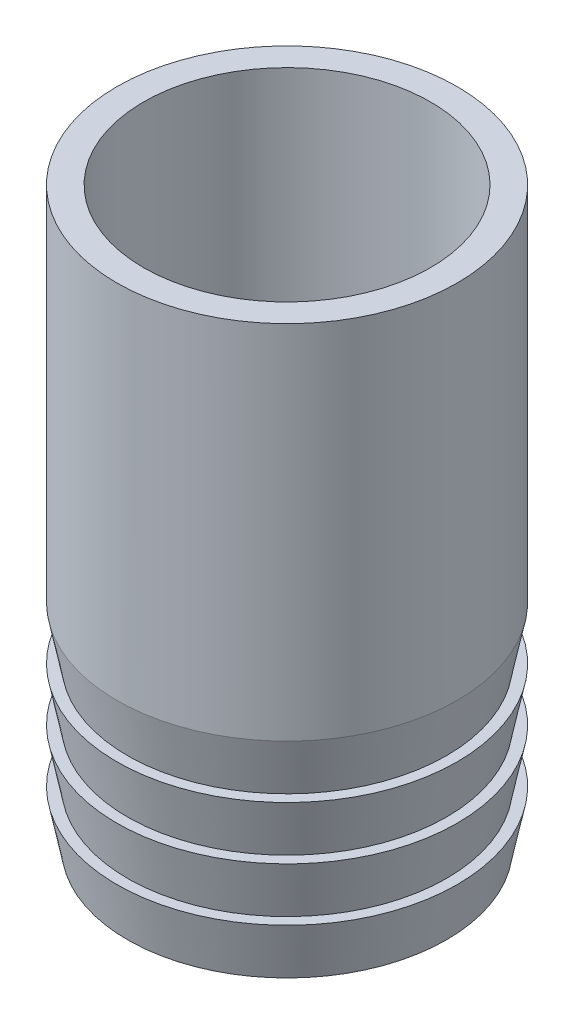
from build123d import *

# Parameters (mm, degrees)
SKETCH1_R           = 16
SKETCH1_R_2         = 13.5
BOSS_EXTRUDE1_DEPTH = 54


with BuildPart() as part:
    # Sketch1 → Boss-Extrude1 (new body)
    with BuildSketch(Plane(origin=(0, 0, 0), x_dir=(1, 0, 0), z_dir=(0, 1, 0))):
        Circle(SKETCH1_R)
        Circle(SKETCH1_R_2, mode=Mode.SUBTRACT)
    extrude(amount=BOSS_EXTRUDE1_DEPTH)

    # Sketch2 → Cut-Revolve2 (revolve, cut)
    with BuildSketch(Plane.XY):
        Polygon((16, 15), (16, 20), (15, 15), align=None)
        Polygon((16, 0), (16, 5), (15, 0), align=None)
        Polygon((16, 5), (16, 10), (15, 5), align=None)
        Polygon((16, 10), (16, 15), (15, 10), align=None)
    revolve(axis=Axis((0, 0, 0), (0, 1, 0)), mode=Mode.SUBTRACT)


solid = part.part
